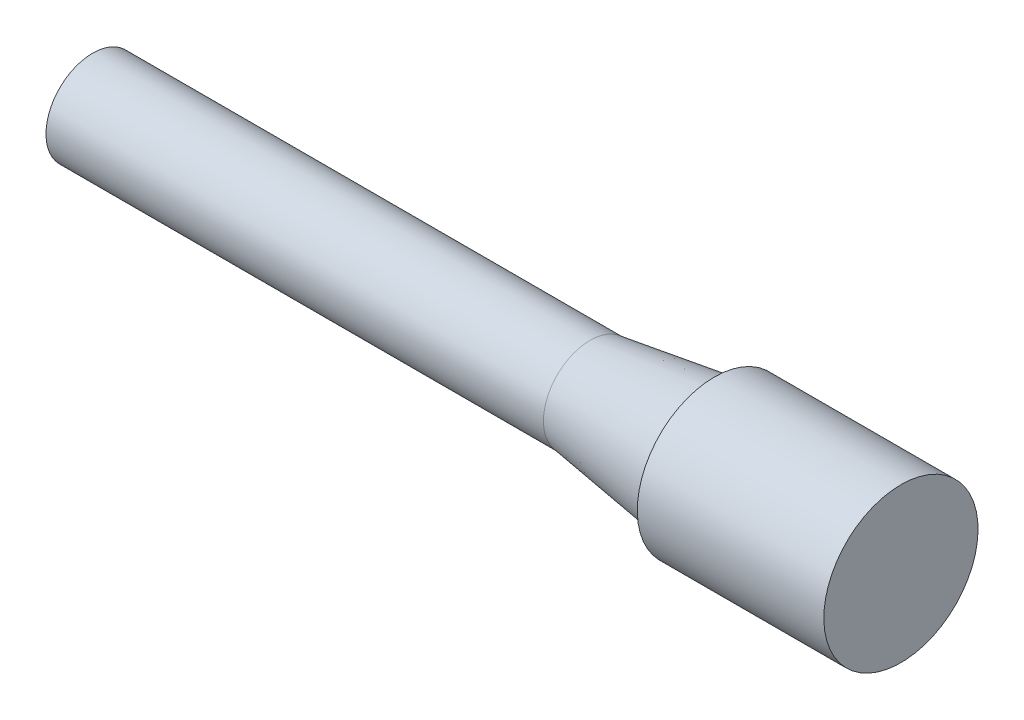
from build123d import *


with BuildPart() as part:
    # Sketch1 → Revolve1 (revolve)
    with BuildSketch(Plane.XY):
        Polygon((0, 0), (-82.55, 0), (-82.55, 4.7625), (-31.75, 4.7625), (-19.05, 6.604), (-19.05, 7.874), (0, 7.874), align=None)
    revolve(axis=Axis((0, 0, 0), (-1, 0, 0)))


solid = part.part
